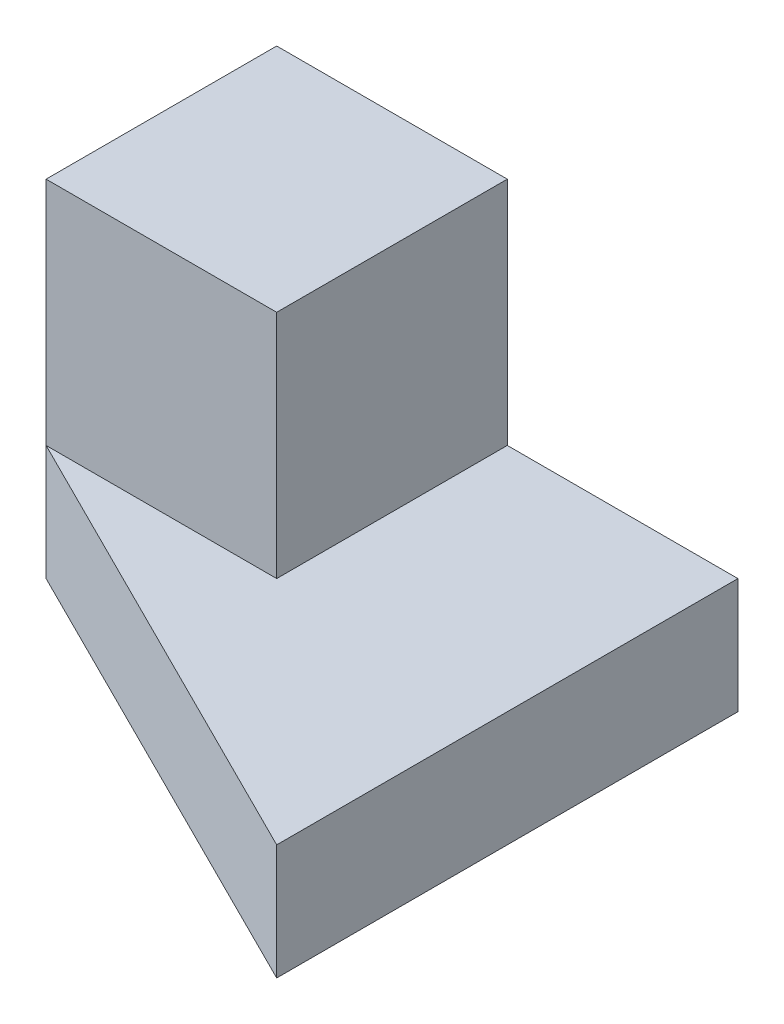
from build123d import *

# Parameters (mm, degrees)
SKETCH_1_W      = 10
SKETCH_1_H      = 10
EXTRUDE_1_DEPTH = 15
EXTRUDE_2_DEPTH = 5


with BuildPart() as part:
    # 草圖1 → 填料-伸長1 (new body)
    with BuildSketch(Plane(origin=(0, 0, 0), x_dir=(1, 0, 0), z_dir=(0, 1, 0))):
        with Locations((5, 5)):
            Rectangle(SKETCH_1_W, SKETCH_1_H)
    extrude(amount=EXTRUDE_1_DEPTH)

    # 草圖1<3> → 填料-伸長2 (add)
    with BuildSketch(Plane(origin=(0, 0, 0), x_dir=(1, 0, 0), z_dir=(0, 1, 0))):
        Polygon((10, 0), (0, 0), (20, -10), (20, 10), (10, 10), align=None)
    extrude(amount=EXTRUDE_2_DEPTH)


solid = part.part
